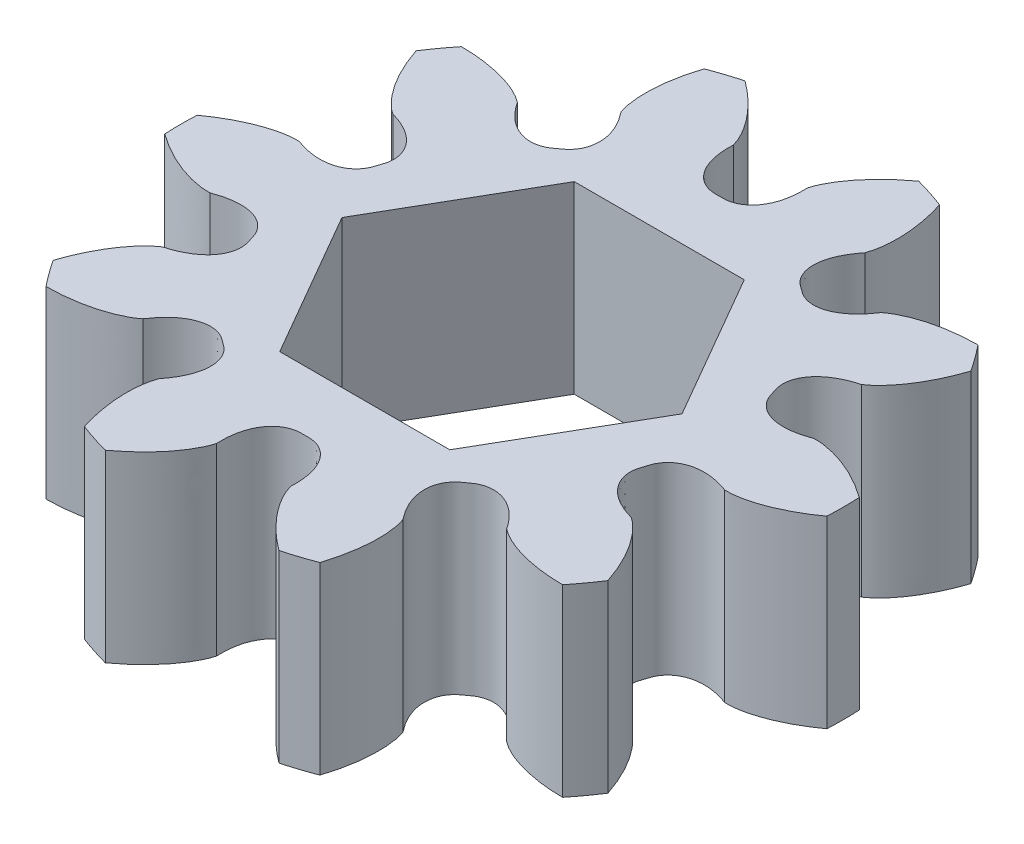
from build123d import *

# Parameters (mm, degrees)
BOSS_EXTRUDE1_DEPTH = 3
SCALE1_SCALE_X      = 0.9
SCALE1_SCALE_Y      = 1
SCALE1_SCALE_Z      = 0.9
CUT_EXTRUDE1_DEPTH  = 10


with BuildPart() as part:
    # Sketch1 → Boss-Extrude1 (new body)
    with BuildSketch(Plane(origin=(0, 0, 0), x_dir=(1, 0, 0), z_dir=(0, 1, 0))):
        with BuildLine():
            ThreePointArc((-2.131306836, -5.60870138), (-1.854101966, -5.706339098), (-1.572448505, -5.790285459))
            add(Edge.make_bspline(
                [(-1.572448505, -5.790285459), (-1.524121757, -5.753776421), (-1.427468014, -5.680758158), (-1.29005992, -5.561733251), (-1.159069112, -5.435753819), (-1.036126032, -5.301847985), (-0.92251263, -5.159932716), (-0.837301737, -5.034588255), (-0.776335293, -4.929887877), (-0.735125884, -4.848929659), (-0.698268351, -4.765746753), (-0.680638314, -4.707778502), (-0.671824783, -4.678799267)],
                knots=[0, 0, 0, 0, 0.010251706, 0.020503464, 0.030755047, 0.041006321, 0.051257106, 0.061507029, 0.066633012, 0.071758798, 0.07688417, 0.082007812, 0.082007812, 0.082007812, 0.082007812], degree=3, weights=[1, 1, 1, 1, 1, 1, 1, 1, 1, 1, 1, 1, 1]))
            add(Edge.make_bspline(
                [(-0.671824783, -4.678799267), (-0.672788438, -4.651496326), (-0.674715723, -4.596891171), (-0.67266211, -4.514929148), (-0.666126837, -4.433177326), (-0.653115793, -4.352246289), (-0.637164096, -4.271797271), (-0.612712294, -4.193474838), (-0.58299038, -4.117042318), (-0.545673731, -4.043909177), (-0.500291897, -3.975487721), (-0.447276365, -3.912783717), (-0.386261642, -3.857704877), (-0.317525574, -3.812703152), (-0.243061735, -3.777838125), (-0.176887172, -3.760110426), (-0.122948454, -3.751154668), (-0.068263798, -3.749181842), (0, -3.750545471), (0.068263798, -3.749181842), (0.122948454, -3.751154668), (0.176887172, -3.760110426), (0.243061735, -3.777838125), (0.317525574, -3.812703152), (0.386261642, -3.857704877), (0.447276365, -3.912783717), (0.500291897, -3.975487721), (0.545673731, -4.043909177), (0.58299038, -4.117042318), (0.612712294, -4.193474838), (0.637164096, -4.271797271), (0.653115793, -4.352246289), (0.666126837, -4.433177326), (0.67266211, -4.514929148), (0.674715723, -4.596891171), (0.672788438, -4.651496326), (0.671824783, -4.678799267)],
                knots=[0, 0, 0, 0, 0.003643402, 0.007286706, 0.010929975, 0.01457286, 0.01821558, 0.021858686, 0.025500936, 0.029144127, 0.032787024, 0.036428762, 0.040069815, 0.043709849, 0.04734977, 0.050988094, 0.052810356, 0.054631699, 0.058275045, 0.061918391, 0.063739733, 0.065561995, 0.069200319, 0.07284024, 0.076480275, 0.080121327, 0.083763065, 0.087405962, 0.091049153, 0.094691403, 0.098334509, 0.101977229, 0.105620114, 0.109263383, 0.112906688, 0.116550089, 0.116550089, 0.116550089, 0.116550089], degree=3, weights=[1, 1, 1, 1, 1, 1, 1, 1, 1, 1, 1, 1, 1, 1, 1, 1, 1, 1, 1, 1, 1, 1, 1, 1, 1, 1, 1, 1, 1, 1, 1, 1, 1, 1, 1, 1, 1]))
            add(Edge.make_bspline(
                [(0.671824783, -4.678799267), (0.680638314, -4.707778502), (0.698268351, -4.765746753), (0.735125884, -4.848929659), (0.776335293, -4.929887877), (0.837301737, -5.034588255), (0.92251263, -5.159932716), (1.036126032, -5.301847985), (1.159069112, -5.435753819), (1.29005992, -5.561733251), (1.427468014, -5.680758158), (1.524121757, -5.753776421), (1.572448505, -5.790285459)],
                knots=[0, 0, 0, 0, 0.002373455, 0.004747711, 0.007122158, 0.009496697, 0.014244829, 0.01899336, 0.023742117, 0.028491018, 0.03324, 0.037988957, 0.037988957, 0.037988957, 0.037988957], degree=3, weights=[1, 1, 1, 1, 1, 1, 1, 1, 1, 1, 1, 1, 1]))
            ThreePointArc((1.572448505, -5.790285459), (1.854101966, -5.706339098), (2.131306836, -5.60870138))
            add(Edge.make_bspline(
                [(2.131306836, -5.60870138), (2.148944522, -5.550759198), (2.184219984, -5.434874537), (2.225424383, -5.257814913), (2.25734932, -5.078900947), (2.278104487, -4.898304722), (2.286603958, -4.716712576), (2.281865393, -4.565221071), (2.269646944, -4.444681509), (2.25540001, -4.354962652), (2.236324695, -4.266001953), (2.216514811, -4.208741977), (2.206611541, -4.180116819)],
                knots=[0, 0, 0, 0, 0.018166013, 0.036332118, 0.054497913, 0.072663161, 0.090827541, 0.108990394, 0.11807363, 0.127156519, 0.136238672, 0.145317761, 0.145317761, 0.145317761, 0.145317761], degree=3, weights=[1, 1, 1, 1, 1, 1, 1, 1, 1, 1, 1, 1, 1]))
            add(Edge.make_bspline(
                [(2.206611541, -4.180116819), (2.189783662, -4.158594699), (2.156128351, -4.11555103), (2.10961369, -4.048035277), (2.066848322, -3.978055327), (2.029804408, -3.904933043), (1.995422855, -3.830472247), (1.969168007, -3.75273566), (1.948287632, -3.673430349), (1.935490854, -3.592330219), (1.931988406, -3.510301326), (1.938022384, -3.428410974), (1.955009802, -3.347987702), (1.984167098, -3.271178494), (2.023916461, -3.199203349), (2.067032727, -3.145964907), (2.105406004, -3.107015163), (2.148487222, -3.073276279), (2.204515316, -3.034255025), (2.258940368, -2.993027372), (2.304340782, -2.962480587), (2.353242184, -2.938021565), (2.41719861, -2.913467142), (2.49793427, -2.897904795), (2.579994267, -2.893909908), (2.661730745, -2.902606072), (2.7414777, -2.922172928), (2.818409497, -2.950852276), (2.891585883, -2.988084054), (2.960557324, -3.032449159), (3.026376018, -3.08144093), (3.086567959, -3.137149381), (3.144664185, -3.194976265), (3.198003847, -3.257273541), (3.247841323, -3.322375128), (3.278378222, -3.367684455), (3.293646874, -3.39033942)],
                knots=[0, 0, 0, 0, 0.008194405, 0.016388591, 0.024582696, 0.03277594, 0.040968812, 0.04916255, 0.057354364, 0.065548295, 0.073741565, 0.081932227, 0.090121349, 0.09830818, 0.106494756, 0.114677741, 0.118776206, 0.122872602, 0.131066881, 0.139261161, 0.143357557, 0.147456021, 0.155639006, 0.163825582, 0.172012413, 0.180201535, 0.188392198, 0.196585467, 0.204779398, 0.212971212, 0.221164951, 0.229357823, 0.237551066, 0.245745171, 0.253939358, 0.262133762, 0.262133762, 0.262133762, 0.262133762], degree=3, weights=[1, 1, 1, 1, 1, 1, 1, 1, 1, 1, 1, 1, 1, 1, 1, 1, 1, 1, 1, 1, 1, 1, 1, 1, 1, 1, 1, 1, 1, 1, 1, 1, 1, 1, 1, 1, 1]))
            add(Edge.make_bspline(
                [(3.293646874, -3.39033942), (3.317810738, -3.408603651), (3.36614662, -3.445138275), (3.444858677, -3.490770346), (3.525783835, -3.532044637), (3.636648062, -3.580913845), (3.779260749, -3.632233938), (3.954591624, -3.68026552), (4.132762539, -3.716333486), (4.312785181, -3.741258522), (4.493911749, -3.756785244), (4.615025328, -3.759046615), (4.675581963, -3.760177297)],
                knots=[0, 0, 0, 0, 0.009079089, 0.018161243, 0.027244131, 0.036327367, 0.05449022, 0.072654601, 0.090819848, 0.108985643, 0.127151749, 0.145317761, 0.145317761, 0.145317761, 0.145317761], degree=3, weights=[1, 1, 1, 1, 1, 1, 1, 1, 1, 1, 1, 1, 1]))
            ThreePointArc((4.675581963, -3.760177297), (4.854101966, -3.526711514), (5.020975406, -3.284784006))
            add(Edge.make_bspline(
                [(5.020975406, -3.284784006), (5.001187034, -3.227540624), (4.961610188, -3.113053568), (4.890872211, -2.945589986), (4.811537037, -2.782080539), (4.722176522, -2.623775544), (4.622315553, -2.471868547), (4.529437501, -2.352094604), (4.448701191, -2.261757874), (4.384439758, -2.197547932), (4.316717717, -2.136789403), (4.267034616, -2.102109067), (4.242197256, -2.084771824)],
                knots=[0, 0, 0, 0, 0.018166013, 0.036332118, 0.054497913, 0.072663161, 0.090827541, 0.108990394, 0.11807363, 0.127156519, 0.136238672, 0.145317761, 0.145317761, 0.145317761, 0.145317761], degree=3, weights=[1, 1, 1, 1, 1, 1, 1, 1, 1, 1, 1, 1, 1]))
            add(Edge.make_bspline(
                [(4.242197256, -2.084771824), (4.215932831, -2.077251242), (4.163404679, -2.062210278), (4.086088763, -2.034929518), (4.010357671, -2.003451402), (3.937408315, -1.966068098), (3.865826097, -1.926037018), (3.798893059, -1.87857901), (3.735385989, -1.826692843), (3.677363718, -1.768603217), (3.626314804, -1.704299135), (3.583062453, -1.634501765), (3.54953395, -1.559453018), (3.527975379, -1.480174835), (3.51782736, -1.39858163), (3.521416381, -1.33016772), (3.529566929, -1.27610147), (3.544589148, -1.223483634), (3.56698071, -1.158982289), (3.586778496, -1.093638174), (3.605553252, -1.042239612), (3.630738665, -0.993708325), (3.668047774, -0.936250736), (3.724216976, -0.876205302), (3.788256773, -0.824739715), (3.859494449, -0.783731563), (3.935512201, -0.752687398), (4.01460863, -0.730670102), (4.095693859, -0.717779242), (4.177570082, -0.71313097), (4.259615165, -0.714078888), (4.341056073, -0.723768037), (4.422046697, -0.736402864), (4.50181681, -0.755450152), (4.580401928, -0.778824708), (4.631738953, -0.797531586), (4.657407806, -0.806885149)],
                knots=[0, 0, 0, 0, 0.008194405, 0.016388591, 0.024582696, 0.03277594, 0.040968812, 0.04916255, 0.057354364, 0.065548295, 0.073741565, 0.081932227, 0.090121349, 0.09830818, 0.106494756, 0.114677741, 0.118776206, 0.122872602, 0.131066881, 0.139261161, 0.143357557, 0.147456021, 0.155639006, 0.163825582, 0.172012413, 0.180201535, 0.188392198, 0.196585467, 0.204779398, 0.212971212, 0.221164951, 0.229357823, 0.237551066, 0.245745171, 0.253939358, 0.262133762, 0.262133762, 0.262133762, 0.262133762], degree=3, weights=[1, 1, 1, 1, 1, 1, 1, 1, 1, 1, 1, 1, 1, 1, 1, 1, 1, 1, 1, 1, 1, 1, 1, 1, 1, 1, 1, 1, 1, 1, 1, 1, 1, 1, 1, 1, 1]))
            add(Edge.make_bspline(
                [(4.657407806, -0.806885149), (4.687692228, -0.807458059), (4.748271292, -0.808604072), (4.838772541, -0.799255407), (4.928502789, -0.785080395), (5.046918433, -0.759452057), (5.192459714, -0.717145251), (5.362537627, -0.652946714), (5.527881144, -0.577400075), (5.688173089, -0.491750199), (5.843833939, -0.397848055), (5.943146083, -0.328488767), (5.992802028, -0.293809212)],
                knots=[0, 0, 0, 0, 0.009079089, 0.018161243, 0.027244131, 0.036327367, 0.05449022, 0.072654601, 0.090819848, 0.108985643, 0.127151749, 0.145317761, 0.145317761, 0.145317761, 0.145317761], degree=3, weights=[1, 1, 1, 1, 1, 1, 1, 1, 1, 1, 1, 1, 1]))
            ThreePointArc((5.992802028, -0.293809212), (6, 0), (5.992802028, 0.293809212))
            add(Edge.make_bspline(
                [(5.992802028, 0.293809212), (5.943146083, 0.328488767), (5.843833939, 0.397848055), (5.688173089, 0.491750199), (5.527881144, 0.577400075), (5.362537627, 0.652946714), (5.192459714, 0.717145251), (5.046918433, 0.759452057), (4.928502789, 0.785080395), (4.838772541, 0.799255407), (4.748271292, 0.808604072), (4.687692228, 0.807458059), (4.657407806, 0.806885149)],
                knots=[0, 0, 0, 0, 0.018166013, 0.036332118, 0.054497913, 0.072663161, 0.090827541, 0.108990394, 0.11807363, 0.127156519, 0.136238672, 0.145317761, 0.145317761, 0.145317761, 0.145317761], degree=3, weights=[1, 1, 1, 1, 1, 1, 1, 1, 1, 1, 1, 1, 1]))
            add(Edge.make_bspline(
                [(4.657407806, 0.806885149), (4.631738953, 0.797531586), (4.580401928, 0.778824708), (4.50181681, 0.755450152), (4.422046697, 0.736402864), (4.341056073, 0.723768037), (4.259615165, 0.714078888), (4.177570082, 0.71313097), (4.095693859, 0.717779242), (4.01460863, 0.730670102), (3.935512201, 0.752687398), (3.859494449, 0.783731563), (3.788256773, 0.824739715), (3.724216976, 0.876205302), (3.668047774, 0.936250736), (3.630738665, 0.993708325), (3.605553252, 1.042239612), (3.586778496, 1.093638174), (3.56698071, 1.158982289), (3.544589148, 1.223483634), (3.529566929, 1.27610147), (3.521416381, 1.33016772), (3.51782736, 1.39858163), (3.527975379, 1.480174835), (3.54953395, 1.559453018), (3.583062453, 1.634501765), (3.626314804, 1.704299135), (3.677363718, 1.768603217), (3.735385989, 1.826692843), (3.798893059, 1.87857901), (3.865826097, 1.926037018), (3.937408315, 1.966068098), (4.010357671, 2.003451402), (4.086088763, 2.034929518), (4.163404679, 2.062210278), (4.215932831, 2.077251242), (4.242197256, 2.084771824)],
                knots=[0, 0, 0, 0, 0.008194405, 0.016388591, 0.024582696, 0.03277594, 0.040968812, 0.04916255, 0.057354364, 0.065548295, 0.073741565, 0.081932227, 0.090121349, 0.09830818, 0.106494756, 0.114677741, 0.118776206, 0.122872602, 0.131066881, 0.139261161, 0.143357557, 0.147456021, 0.155639006, 0.163825582, 0.172012413, 0.180201535, 0.188392198, 0.196585467, 0.204779398, 0.212971212, 0.221164951, 0.229357823, 0.237551066, 0.245745171, 0.253939358, 0.262133762, 0.262133762, 0.262133762, 0.262133762], degree=3, weights=[1, 1, 1, 1, 1, 1, 1, 1, 1, 1, 1, 1, 1, 1, 1, 1, 1, 1, 1, 1, 1, 1, 1, 1, 1, 1, 1, 1, 1, 1, 1, 1, 1, 1, 1, 1, 1]))
            add(Edge.make_bspline(
                [(4.242197256, 2.084771824), (4.267034616, 2.102109067), (4.316717717, 2.136789403), (4.384439758, 2.197547932), (4.448701191, 2.261757874), (4.529437501, 2.352094604), (4.622315553, 2.471868547), (4.722176522, 2.623775544), (4.811537037, 2.782080539), (4.890872211, 2.945589986), (4.961610188, 3.113053568), (5.001187034, 3.227540624), (5.020975406, 3.284784006)],
                knots=[0, 0, 0, 0, 0.009079089, 0.018161243, 0.027244131, 0.036327367, 0.05449022, 0.072654601, 0.090819848, 0.108985643, 0.127151749, 0.145317761, 0.145317761, 0.145317761, 0.145317761], degree=3, weights=[1, 1, 1, 1, 1, 1, 1, 1, 1, 1, 1, 1, 1]))
            ThreePointArc((5.020975406, 3.284784006), (4.854101966, 3.526711514), (4.675581963, 3.760177297))
            add(Edge.make_bspline(
                [(4.675581963, 3.760177297), (4.615025328, 3.759046615), (4.493911749, 3.756785244), (4.312785181, 3.741258522), (4.132762539, 3.716333486), (3.954591624, 3.68026552), (3.779260749, 3.632233938), (3.636648062, 3.580913845), (3.525783835, 3.532044637), (3.444858677, 3.490770346), (3.36614662, 3.445138275), (3.317810738, 3.408603651), (3.293646874, 3.39033942)],
                knots=[0, 0, 0, 0, 0.018166013, 0.036332118, 0.054497913, 0.072663161, 0.090827541, 0.108990394, 0.11807363, 0.127156519, 0.136238672, 0.145317761, 0.145317761, 0.145317761, 0.145317761], degree=3, weights=[1, 1, 1, 1, 1, 1, 1, 1, 1, 1, 1, 1, 1]))
            add(Edge.make_bspline(
                [(3.293646874, 3.39033942), (3.278378222, 3.367684455), (3.247841323, 3.322375128), (3.198003847, 3.257273541), (3.144664185, 3.194976265), (3.086567959, 3.137149381), (3.026376018, 3.08144093), (2.960557324, 3.032449159), (2.891585883, 2.988084054), (2.818409497, 2.950852276), (2.7414777, 2.922172928), (2.661730745, 2.902606072), (2.579994267, 2.893909908), (2.49793427, 2.897904795), (2.41719861, 2.913467142), (2.353242184, 2.938021565), (2.304340782, 2.962480587), (2.258940368, 2.993027372), (2.204515316, 3.034255025), (2.148487222, 3.073276279), (2.105406004, 3.107015163), (2.067032727, 3.145964907), (2.023916461, 3.199203349), (1.984167098, 3.271178494), (1.955009802, 3.347987702), (1.938022384, 3.428410974), (1.931988406, 3.510301326), (1.935490854, 3.592330219), (1.948287632, 3.673430349), (1.969168007, 3.75273566), (1.995422855, 3.830472247), (2.029804408, 3.904933043), (2.066848322, 3.978055327), (2.10961369, 4.048035277), (2.156128351, 4.11555103), (2.189783662, 4.158594699), (2.206611541, 4.180116819)],
                knots=[0, 0, 0, 0, 0.008194405, 0.016388591, 0.024582696, 0.03277594, 0.040968812, 0.04916255, 0.057354364, 0.065548295, 0.073741565, 0.081932227, 0.090121349, 0.09830818, 0.106494756, 0.114677741, 0.118776206, 0.122872602, 0.131066881, 0.139261161, 0.143357557, 0.147456021, 0.155639006, 0.163825582, 0.172012413, 0.180201535, 0.188392198, 0.196585467, 0.204779398, 0.212971212, 0.221164951, 0.229357823, 0.237551066, 0.245745171, 0.253939358, 0.262133762, 0.262133762, 0.262133762, 0.262133762], degree=3, weights=[1, 1, 1, 1, 1, 1, 1, 1, 1, 1, 1, 1, 1, 1, 1, 1, 1, 1, 1, 1, 1, 1, 1, 1, 1, 1, 1, 1, 1, 1, 1, 1, 1, 1, 1, 1, 1]))
            add(Edge.make_bspline(
                [(2.206611541, 4.180116819), (2.216514811, 4.208741977), (2.236324695, 4.266001953), (2.25540001, 4.354962652), (2.269646944, 4.444681509), (2.281865393, 4.565221071), (2.286603958, 4.716712576), (2.278104487, 4.898304722), (2.25734932, 5.078900947), (2.225424383, 5.257814913), (2.184219984, 5.434874537), (2.148944522, 5.550759198), (2.131306836, 5.60870138)],
                knots=[0, 0, 0, 0, 0.009079089, 0.018161243, 0.027244131, 0.036327367, 0.05449022, 0.072654601, 0.090819848, 0.108985643, 0.127151749, 0.145317761, 0.145317761, 0.145317761, 0.145317761], degree=3, weights=[1, 1, 1, 1, 1, 1, 1, 1, 1, 1, 1, 1, 1]))
            ThreePointArc((2.131306836, 5.60870138), (1.854101966, 5.706339098), (1.572448505, 5.790285459))
            add(Edge.make_bspline(
                [(1.572448505, 5.790285459), (1.524121757, 5.753776421), (1.427468014, 5.680758158), (1.29005992, 5.561733251), (1.159069112, 5.435753819), (1.036126032, 5.301847985), (0.92251263, 5.159932716), (0.837301737, 5.034588255), (0.776335293, 4.929887877), (0.735125884, 4.848929659), (0.698268351, 4.765746753), (0.680638314, 4.707778502), (0.671824783, 4.678799267)],
                knots=[0, 0, 0, 0, 0.018166013, 0.036332118, 0.054497913, 0.072663161, 0.090827541, 0.108990394, 0.11807363, 0.127156519, 0.136238672, 0.145317761, 0.145317761, 0.145317761, 0.145317761], degree=3, weights=[1, 1, 1, 1, 1, 1, 1, 1, 1, 1, 1, 1, 1]))
            add(Edge.make_bspline(
                [(0.671824783, 4.678799267), (0.672788438, 4.651496326), (0.674715723, 4.596891171), (0.67266211, 4.514929148), (0.666126837, 4.433177326), (0.653115793, 4.352246289), (0.637164096, 4.271797271), (0.612712294, 4.193474838), (0.58299038, 4.117042318), (0.545673731, 4.043909177), (0.500291897, 3.975487721), (0.447276365, 3.912783717), (0.386261642, 3.857704877), (0.317525574, 3.812703152), (0.243061735, 3.777838125), (0.176887172, 3.760110426), (0.122948454, 3.751154668), (0.068263798, 3.749181842), (0, 3.750545471), (-0.068263798, 3.749181842), (-0.122948454, 3.751154668), (-0.176887172, 3.760110426), (-0.243061735, 3.777838125), (-0.317525574, 3.812703152), (-0.386261642, 3.857704877), (-0.447276365, 3.912783717), (-0.500291897, 3.975487721), (-0.545673731, 4.043909177), (-0.58299038, 4.117042318), (-0.612712294, 4.193474838), (-0.637164096, 4.271797271), (-0.653115793, 4.352246289), (-0.666126837, 4.433177326), (-0.67266211, 4.514929148), (-0.674715723, 4.596891171), (-0.672788438, 4.651496326), (-0.671824783, 4.678799267)],
                knots=[0, 0, 0, 0, 0.008194405, 0.016388591, 0.024582696, 0.03277594, 0.040968812, 0.04916255, 0.057354364, 0.065548295, 0.073741565, 0.081932227, 0.090121349, 0.09830818, 0.106494756, 0.114677741, 0.118776206, 0.122872602, 0.131066881, 0.139261161, 0.143357557, 0.147456021, 0.155639006, 0.163825582, 0.172012413, 0.180201535, 0.188392198, 0.196585467, 0.204779398, 0.212971212, 0.221164951, 0.229357823, 0.237551066, 0.245745171, 0.253939358, 0.262133762, 0.262133762, 0.262133762, 0.262133762], degree=3, weights=[1, 1, 1, 1, 1, 1, 1, 1, 1, 1, 1, 1, 1, 1, 1, 1, 1, 1, 1, 1, 1, 1, 1, 1, 1, 1, 1, 1, 1, 1, 1, 1, 1, 1, 1, 1, 1]))
            add(Edge.make_bspline(
                [(-0.671824783, 4.678799267), (-0.680638314, 4.707778502), (-0.698268351, 4.765746753), (-0.735125884, 4.848929659), (-0.776335293, 4.929887877), (-0.837301737, 5.034588255), (-0.92251263, 5.159932716), (-1.036126032, 5.301847985), (-1.159069112, 5.435753819), (-1.29005992, 5.561733251), (-1.427468014, 5.680758158), (-1.524121757, 5.753776421), (-1.572448505, 5.790285459)],
                knots=[0, 0, 0, 0, 0.009079089, 0.018161243, 0.027244131, 0.036327367, 0.05449022, 0.072654601, 0.090819848, 0.108985643, 0.127151749, 0.145317761, 0.145317761, 0.145317761, 0.145317761], degree=3, weights=[1, 1, 1, 1, 1, 1, 1, 1, 1, 1, 1, 1, 1]))
            ThreePointArc((-1.572448505, 5.790285459), (-1.854101966, 5.706339098), (-2.131306836, 5.60870138))
            add(Edge.make_bspline(
                [(-2.131306836, 5.60870138), (-2.148944522, 5.550759198), (-2.184219984, 5.434874537), (-2.225424383, 5.257814913), (-2.25734932, 5.078900947), (-2.278104487, 4.898304722), (-2.286603958, 4.716712576), (-2.281865393, 4.565221071), (-2.269646944, 4.444681509), (-2.25540001, 4.354962652), (-2.236324695, 4.266001953), (-2.216514811, 4.208741977), (-2.206611541, 4.180116819)],
                knots=[0, 0, 0, 0, 0.018166013, 0.036332118, 0.054497913, 0.072663161, 0.090827541, 0.108990394, 0.11807363, 0.127156519, 0.136238672, 0.145317761, 0.145317761, 0.145317761, 0.145317761], degree=3, weights=[1, 1, 1, 1, 1, 1, 1, 1, 1, 1, 1, 1, 1]))
            add(Edge.make_bspline(
                [(-2.206611541, 4.180116819), (-2.189783662, 4.158594699), (-2.156128351, 4.11555103), (-2.10961369, 4.048035277), (-2.066848322, 3.978055327), (-2.029804408, 3.904933043), (-1.995422855, 3.830472247), (-1.969168007, 3.75273566), (-1.948287632, 3.673430349), (-1.935490854, 3.592330219), (-1.931988406, 3.510301326), (-1.938022384, 3.428410974), (-1.955009802, 3.347987702), (-1.984167098, 3.271178494), (-2.023916461, 3.199203349), (-2.067032727, 3.145964907), (-2.105406004, 3.107015163), (-2.148487222, 3.073276279), (-2.204515316, 3.034255025), (-2.258940368, 2.993027372), (-2.304340782, 2.962480587), (-2.353242184, 2.938021565), (-2.41719861, 2.913467142), (-2.49793427, 2.897904795), (-2.579994267, 2.893909908), (-2.661730745, 2.902606072), (-2.7414777, 2.922172928), (-2.818409497, 2.950852276), (-2.891585883, 2.988084054), (-2.960557324, 3.032449159), (-3.026376018, 3.08144093), (-3.086567959, 3.137149381), (-3.144664185, 3.194976265), (-3.198003847, 3.257273541), (-3.247841323, 3.322375128), (-3.278378222, 3.367684455), (-3.293646874, 3.39033942)],
                knots=[0, 0, 0, 0, 0.008194405, 0.016388591, 0.024582696, 0.03277594, 0.040968812, 0.04916255, 0.057354364, 0.065548295, 0.073741565, 0.081932227, 0.090121349, 0.09830818, 0.106494756, 0.114677741, 0.118776206, 0.122872602, 0.131066881, 0.139261161, 0.143357557, 0.147456021, 0.155639006, 0.163825582, 0.172012413, 0.180201535, 0.188392198, 0.196585467, 0.204779398, 0.212971212, 0.221164951, 0.229357823, 0.237551066, 0.245745171, 0.253939358, 0.262133762, 0.262133762, 0.262133762, 0.262133762], degree=3, weights=[1, 1, 1, 1, 1, 1, 1, 1, 1, 1, 1, 1, 1, 1, 1, 1, 1, 1, 1, 1, 1, 1, 1, 1, 1, 1, 1, 1, 1, 1, 1, 1, 1, 1, 1, 1, 1]))
            add(Edge.make_bspline(
                [(-3.293646874, 3.39033942), (-3.317810738, 3.408603651), (-3.36614662, 3.445138275), (-3.444858677, 3.490770346), (-3.525783835, 3.532044637), (-3.636648062, 3.580913845), (-3.779260749, 3.632233938), (-3.954591624, 3.68026552), (-4.132762539, 3.716333486), (-4.312785181, 3.741258522), (-4.493911749, 3.756785244), (-4.615025328, 3.759046615), (-4.675581963, 3.760177297)],
                knots=[0, 0, 0, 0, 0.009079089, 0.018161243, 0.027244131, 0.036327367, 0.05449022, 0.072654601, 0.090819848, 0.108985643, 0.127151749, 0.145317761, 0.145317761, 0.145317761, 0.145317761], degree=3, weights=[1, 1, 1, 1, 1, 1, 1, 1, 1, 1, 1, 1, 1]))
            ThreePointArc((-4.675581963, 3.760177297), (-4.854101966, 3.526711514), (-5.020975406, 3.284784006))
            add(Edge.make_bspline(
                [(-5.020975406, 3.284784006), (-5.001187034, 3.227540624), (-4.961610188, 3.113053568), (-4.890872211, 2.945589986), (-4.811537037, 2.782080539), (-4.722176522, 2.623775544), (-4.622315553, 2.471868547), (-4.529437501, 2.352094604), (-4.448701191, 2.261757874), (-4.384439758, 2.197547932), (-4.316717717, 2.136789403), (-4.267034616, 2.102109067), (-4.242197256, 2.084771824)],
                knots=[0, 0, 0, 0, 0.018166013, 0.036332118, 0.054497913, 0.072663161, 0.090827541, 0.108990394, 0.11807363, 0.127156519, 0.136238672, 0.145317761, 0.145317761, 0.145317761, 0.145317761], degree=3, weights=[1, 1, 1, 1, 1, 1, 1, 1, 1, 1, 1, 1, 1]))
            add(Edge.make_bspline(
                [(-4.242197256, 2.084771824), (-4.215932831, 2.077251242), (-4.163404679, 2.062210278), (-4.086088763, 2.034929518), (-4.010357671, 2.003451402), (-3.937408315, 1.966068098), (-3.865826097, 1.926037018), (-3.798893059, 1.87857901), (-3.735385989, 1.826692843), (-3.677363718, 1.768603217), (-3.626314804, 1.704299135), (-3.583062453, 1.634501765), (-3.54953395, 1.559453018), (-3.527975379, 1.480174835), (-3.51782736, 1.39858163), (-3.521416381, 1.33016772), (-3.529566929, 1.27610147), (-3.544589148, 1.223483634), (-3.56698071, 1.158982289), (-3.586778496, 1.093638174), (-3.605553252, 1.042239612), (-3.630738665, 0.993708325), (-3.668047774, 0.936250736), (-3.724216976, 0.876205302), (-3.788256773, 0.824739715), (-3.859494449, 0.783731563), (-3.935512201, 0.752687398), (-4.01460863, 0.730670102), (-4.095693859, 0.717779242), (-4.177570082, 0.71313097), (-4.259615165, 0.714078888), (-4.341056073, 0.723768037), (-4.422046697, 0.736402864), (-4.50181681, 0.755450152), (-4.580401928, 0.778824708), (-4.631738953, 0.797531586), (-4.657407806, 0.806885149)],
                knots=[0, 0, 0, 0, 0.008194405, 0.016388591, 0.024582696, 0.03277594, 0.040968812, 0.04916255, 0.057354364, 0.065548295, 0.073741565, 0.081932227, 0.090121349, 0.09830818, 0.106494756, 0.114677741, 0.118776206, 0.122872602, 0.131066881, 0.139261161, 0.143357557, 0.147456021, 0.155639006, 0.163825582, 0.172012413, 0.180201535, 0.188392198, 0.196585467, 0.204779398, 0.212971212, 0.221164951, 0.229357823, 0.237551066, 0.245745171, 0.253939358, 0.262133762, 0.262133762, 0.262133762, 0.262133762], degree=3, weights=[1, 1, 1, 1, 1, 1, 1, 1, 1, 1, 1, 1, 1, 1, 1, 1, 1, 1, 1, 1, 1, 1, 1, 1, 1, 1, 1, 1, 1, 1, 1, 1, 1, 1, 1, 1, 1]))
            add(Edge.make_bspline(
                [(-4.657407806, 0.806885149), (-4.687692228, 0.807458059), (-4.748271292, 0.808604072), (-4.838772541, 0.799255407), (-4.928502789, 0.785080395), (-5.046918433, 0.759452057), (-5.192459714, 0.717145251), (-5.362537627, 0.652946714), (-5.527881144, 0.577400075), (-5.688173089, 0.491750199), (-5.843833939, 0.397848055), (-5.943146083, 0.328488767), (-5.992802028, 0.293809212)],
                knots=[0, 0, 0, 0, 0.009079089, 0.018161243, 0.027244131, 0.036327367, 0.05449022, 0.072654601, 0.090819848, 0.108985643, 0.127151749, 0.145317761, 0.145317761, 0.145317761, 0.145317761], degree=3, weights=[1, 1, 1, 1, 1, 1, 1, 1, 1, 1, 1, 1, 1]))
            ThreePointArc((-5.992802028, 0.293809212), (-6, 0), (-5.992802028, -0.293809212))
            add(Edge.make_bspline(
                [(-5.992802028, -0.293809212), (-5.943146083, -0.328488767), (-5.843833939, -0.397848055), (-5.688173089, -0.491750199), (-5.527881144, -0.577400075), (-5.362537627, -0.652946714), (-5.192459714, -0.717145251), (-5.046918433, -0.759452057), (-4.928502789, -0.785080395), (-4.838772541, -0.799255407), (-4.748271292, -0.808604072), (-4.687692228, -0.807458059), (-4.657407806, -0.806885149)],
                knots=[0, 0, 0, 0, 0.018166013, 0.036332118, 0.054497913, 0.072663161, 0.090827541, 0.108990394, 0.11807363, 0.127156519, 0.136238672, 0.145317761, 0.145317761, 0.145317761, 0.145317761], degree=3, weights=[1, 1, 1, 1, 1, 1, 1, 1, 1, 1, 1, 1, 1]))
            add(Edge.make_bspline(
                [(-4.657407806, -0.806885149), (-4.631738953, -0.797531586), (-4.580401928, -0.778824708), (-4.50181681, -0.755450152), (-4.422046697, -0.736402864), (-4.341056073, -0.723768037), (-4.259615165, -0.714078888), (-4.177570082, -0.71313097), (-4.095693859, -0.717779242), (-4.01460863, -0.730670102), (-3.935512201, -0.752687398), (-3.859494449, -0.783731563), (-3.788256773, -0.824739715), (-3.724216976, -0.876205302), (-3.668047774, -0.936250736), (-3.630738665, -0.993708325), (-3.605553252, -1.042239612), (-3.586778496, -1.093638174), (-3.56698071, -1.158982289), (-3.544589148, -1.223483634), (-3.529566929, -1.27610147), (-3.521416381, -1.33016772), (-3.51782736, -1.39858163), (-3.527975379, -1.480174835), (-3.54953395, -1.559453018), (-3.583062453, -1.634501765), (-3.626314804, -1.704299135), (-3.677363718, -1.768603217), (-3.735385989, -1.826692843), (-3.798893059, -1.87857901), (-3.865826097, -1.926037018), (-3.937408315, -1.966068098), (-4.010357671, -2.003451402), (-4.086088763, -2.034929518), (-4.163404679, -2.062210278), (-4.215932831, -2.077251242), (-4.242197256, -2.084771824)],
                knots=[0, 0, 0, 0, 0.008194405, 0.016388591, 0.024582696, 0.03277594, 0.040968812, 0.04916255, 0.057354364, 0.065548295, 0.073741565, 0.081932227, 0.090121349, 0.09830818, 0.106494756, 0.114677741, 0.118776206, 0.122872602, 0.131066881, 0.139261161, 0.143357557, 0.147456021, 0.155639006, 0.163825582, 0.172012413, 0.180201535, 0.188392198, 0.196585467, 0.204779398, 0.212971212, 0.221164951, 0.229357823, 0.237551066, 0.245745171, 0.253939358, 0.262133762, 0.262133762, 0.262133762, 0.262133762], degree=3, weights=[1, 1, 1, 1, 1, 1, 1, 1, 1, 1, 1, 1, 1, 1, 1, 1, 1, 1, 1, 1, 1, 1, 1, 1, 1, 1, 1, 1, 1, 1, 1, 1, 1, 1, 1, 1, 1]))
            add(Edge.make_bspline(
                [(-4.242197256, -2.084771824), (-4.267034616, -2.102109067), (-4.316717717, -2.136789403), (-4.384439758, -2.197547932), (-4.448701191, -2.261757874), (-4.529437501, -2.352094604), (-4.622315553, -2.471868547), (-4.722176522, -2.623775544), (-4.811537037, -2.782080539), (-4.890872211, -2.945589986), (-4.961610188, -3.113053568), (-5.001187034, -3.227540624), (-5.020975406, -3.284784006)],
                knots=[0, 0, 0, 0, 0.009079089, 0.018161243, 0.027244131, 0.036327367, 0.05449022, 0.072654601, 0.090819848, 0.108985643, 0.127151749, 0.145317761, 0.145317761, 0.145317761, 0.145317761], degree=3, weights=[1, 1, 1, 1, 1, 1, 1, 1, 1, 1, 1, 1, 1]))
            ThreePointArc((-5.020975406, -3.284784006), (-4.854101966, -3.526711514), (-4.675581963, -3.760177297))
            add(Edge.make_bspline(
                [(-4.675581963, -3.760177297), (-4.615025328, -3.759046615), (-4.493911749, -3.756785244), (-4.312785181, -3.741258522), (-4.132762539, -3.716333486), (-3.954591624, -3.68026552), (-3.779260749, -3.632233938), (-3.636648062, -3.580913845), (-3.525783835, -3.532044637), (-3.444858677, -3.490770346), (-3.36614662, -3.445138275), (-3.317810738, -3.408603651), (-3.293646874, -3.39033942)],
                knots=[0, 0, 0, 0, 0.018166013, 0.036332118, 0.054497913, 0.072663161, 0.090827541, 0.108990394, 0.11807363, 0.127156519, 0.136238672, 0.145317761, 0.145317761, 0.145317761, 0.145317761], degree=3, weights=[1, 1, 1, 1, 1, 1, 1, 1, 1, 1, 1, 1, 1]))
            add(Edge.make_bspline(
                [(-3.293646874, -3.39033942), (-3.278378222, -3.367684455), (-3.247841323, -3.322375128), (-3.198003847, -3.257273541), (-3.144664185, -3.194976265), (-3.086567959, -3.137149381), (-3.026376018, -3.08144093), (-2.960557324, -3.032449159), (-2.891585883, -2.988084054), (-2.818409497, -2.950852276), (-2.7414777, -2.922172928), (-2.661730745, -2.902606072), (-2.579994267, -2.893909908), (-2.49793427, -2.897904795), (-2.41719861, -2.913467142), (-2.353242184, -2.938021565), (-2.304340782, -2.962480587), (-2.258940368, -2.993027372), (-2.204515316, -3.034255025), (-2.148487222, -3.073276279), (-2.105406004, -3.107015163), (-2.067032727, -3.145964907), (-2.023916461, -3.199203349), (-1.984167098, -3.271178494), (-1.955009802, -3.347987702), (-1.938022384, -3.428410974), (-1.931988406, -3.510301326), (-1.935490854, -3.592330219), (-1.948287632, -3.673430349), (-1.969168007, -3.75273566), (-1.995422855, -3.830472247), (-2.029804408, -3.904933043), (-2.066848322, -3.978055327), (-2.10961369, -4.048035277), (-2.156128351, -4.11555103), (-2.189783662, -4.158594699), (-2.206611541, -4.180116819)],
                knots=[0, 0, 0, 0, 0.008194405, 0.016388591, 0.024582696, 0.03277594, 0.040968812, 0.04916255, 0.057354364, 0.065548295, 0.073741565, 0.081932227, 0.090121349, 0.09830818, 0.106494756, 0.114677741, 0.118776206, 0.122872602, 0.131066881, 0.139261161, 0.143357557, 0.147456021, 0.155639006, 0.163825582, 0.172012413, 0.180201535, 0.188392198, 0.196585467, 0.204779398, 0.212971212, 0.221164951, 0.229357823, 0.237551066, 0.245745171, 0.253939358, 0.262133762, 0.262133762, 0.262133762, 0.262133762], degree=3, weights=[1, 1, 1, 1, 1, 1, 1, 1, 1, 1, 1, 1, 1, 1, 1, 1, 1, 1, 1, 1, 1, 1, 1, 1, 1, 1, 1, 1, 1, 1, 1, 1, 1, 1, 1, 1, 1]))
            add(Edge.make_bspline(
                [(-2.206611541, -4.180116819), (-2.216514811, -4.208741977), (-2.236324695, -4.266001953), (-2.25540001, -4.354962652), (-2.269646944, -4.444681509), (-2.281865393, -4.565221071), (-2.286603958, -4.716712576), (-2.278104487, -4.898304722), (-2.25734932, -5.078900947), (-2.225424383, -5.257814913), (-2.184219984, -5.434874537), (-2.148944522, -5.550759198), (-2.131306836, -5.60870138)],
                knots=[0, 0, 0, 0, 0.009079089, 0.018161243, 0.027244131, 0.036327367, 0.05449022, 0.072654601, 0.090819848, 0.108985643, 0.127151749, 0.145317761, 0.145317761, 0.145317761, 0.145317761], degree=3, weights=[1, 1, 1, 1, 1, 1, 1, 1, 1, 1, 1, 1, 1]))
        make_face()
    extrude(amount=BOSS_EXTRUDE1_DEPTH)


with BuildPart() as part_1:
    # Scale1: scaled about (0, 1.5, 0)
    add(part.part.scale((SCALE1_SCALE_X, SCALE1_SCALE_Y, SCALE1_SCALE_Z), about=(0, 1.5, 0)))

    # Sketch2 → Cut-Extrude1 (cut)
    with BuildSketch(Plane(origin=(0, 3, 0), x_dir=(1, 0, 0), z_dir=(0, 1, 0))):
        Polygon((2.77, 0), (1.385, 2.398890368), (-1.385, 2.398890368), (-2.77, 0), (-1.385, -2.398890368), (1.385, -2.398890368), align=None)
    extrude(amount=-CUT_EXTRUDE1_DEPTH, mode=Mode.SUBTRACT)


solid = part_1.part
